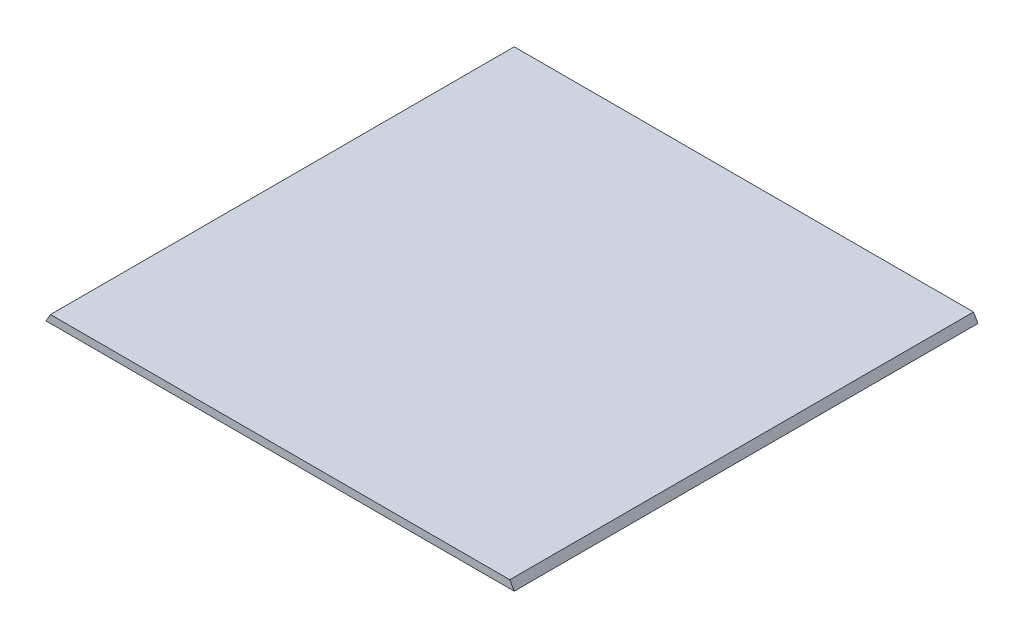
from build123d import *

# Parameters (mm, degrees)
SKETCH1_W           = 381
SKETCH1_H           = 381
BOSS_EXTRUDE1_DEPTH = 6.35
CUT_EXTRUDE1_DEPTH  = 382
BOSS_EXTRUDE2_DEPTH = 381


with BuildPart() as part:
    # Sketch1 → Boss-Extrude1 (new body)
    with BuildSketch(Plane(origin=(0, 0, 0), x_dir=(1, 0, 0), z_dir=(0, 1, 0))):
        with Locations((190.5, -190.5)):
            Rectangle(SKETCH1_W, SKETCH1_H)
    extrude(amount=BOSS_EXTRUDE1_DEPTH)

    # Sketch2 → Cut-Extrude1 (cut, through all)
    with BuildSketch(Plane.XY.offset(381)):
        Polygon((0, 0), (3.666174209, 6.35), (0, 6.35), align=None)
    extrude(amount=-CUT_EXTRUDE1_DEPTH, mode=Mode.SUBTRACT)

    # Sketch5 → Boss-Extrude2 (add)
    with BuildSketch(Plane.XY.offset(381)):
        Polygon((381, 0), (384.666174209, 0), (381, 6.35), align=None)
    extrude(amount=-BOSS_EXTRUDE2_DEPTH)


solid = part.part
